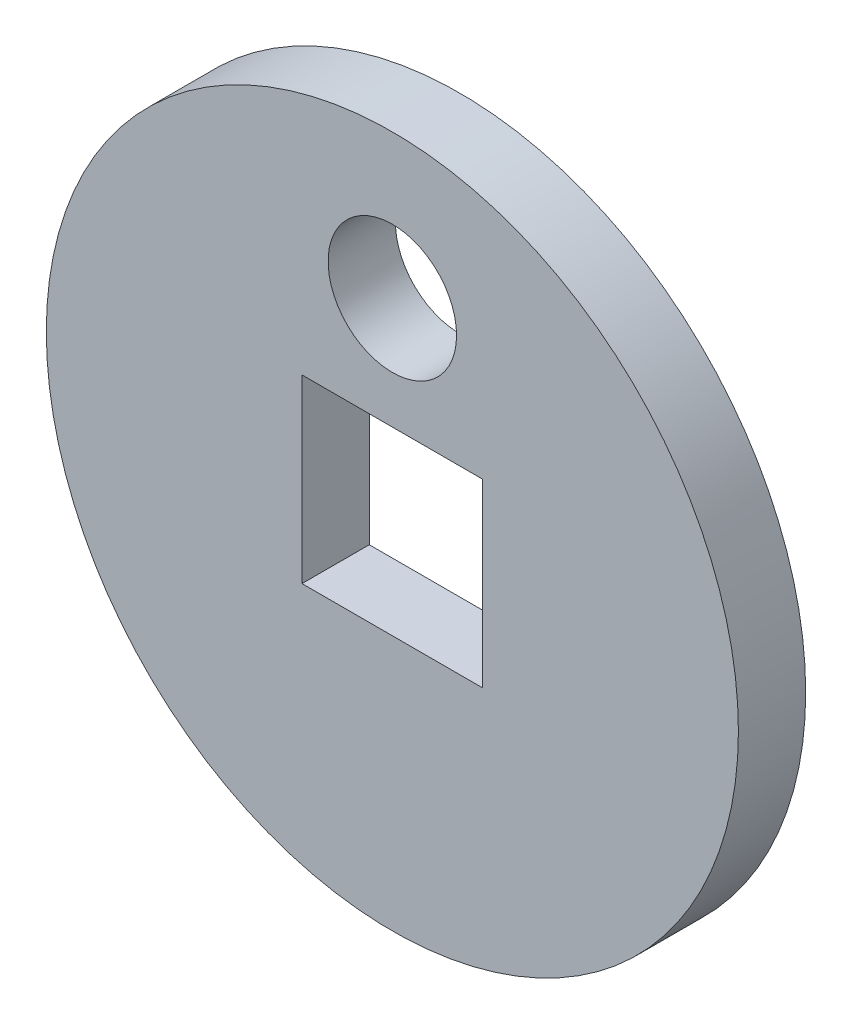
from build123d import *

# Parameters (mm, degrees)
SKETCH1_R           = 9
BOSS_EXTRUDE1_DEPTH = 1.75
SKETCH2_R           = 1.67
SKETCH2_W           = 4.7
SKETCH2_H           = 4.7
CUT_EXTRUDE1_DEPTH  = 2.75


with BuildPart() as part:
    # Sketch1 → Boss-Extrude1 (new body)
    with BuildSketch(Plane.XY):
        Circle(SKETCH1_R)
    extrude(amount=BOSS_EXTRUDE1_DEPTH)

    # Sketch2 → Cut-Extrude1 (cut, through all)
    with BuildSketch(Plane.XY.offset(1.75)):
        with Locations((0, 5.25)):
            Circle(SKETCH2_R)
        Rectangle(SKETCH2_W, SKETCH2_H)
    extrude(amount=-CUT_EXTRUDE1_DEPTH, mode=Mode.SUBTRACT)


solid = part.part
